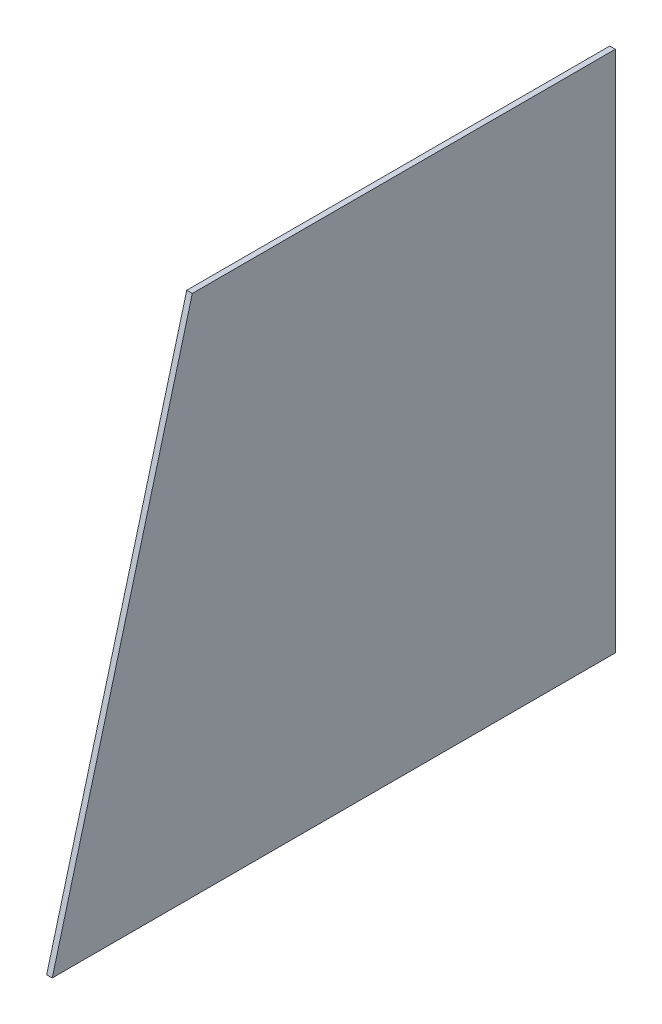
from build123d import *

# Parameters (mm, degrees)
BOSS_EXTRUDE1_DEPTH = 3


with BuildPart() as part:
    # Sketch1 → Boss-Extrude1 (new body)
    with BuildSketch(Plane(origin=(0, 0, 0), x_dir=(0, 0, -1), z_dir=(1, 0, 0))):
        Polygon((-76.274401205, 140.93043534), (151.798793882, 140.93043534), (151.798793882, -140.93043534), (-151.798793882, -140.93043534), align=None)
    extrude(amount=BOSS_EXTRUDE1_DEPTH)


solid = part.part
